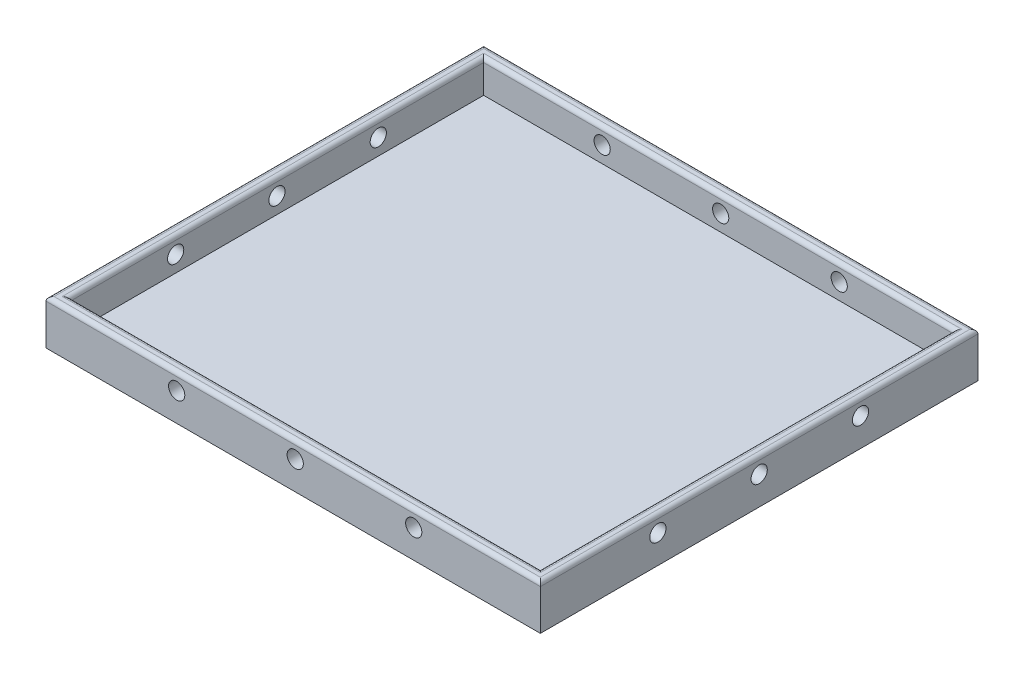
from build123d import *

# Parameters (mm, degrees)
SKETCH1_W               = 122
SKETCH1_H               = 108
BOSS_EXTRUDE1_DEPTH     = 11
SKETCH4_W               = 116
SKETCH4_H               = 102
CUT_EXTRUDE1_DEPTH      = 8
SKETCH6_R               = 1.999999993
SKETCH6_R_2             = 2
CUT_EXTRUDE6_DEPTH      = 120
CUT_EXTRUDE6_DEPTH_BACK = 4
SKETCH5_R               = 2
CUT_EXTRUDE5_DEPTH      = 106
CUT_EXTRUDE5_DEPTH_BACK = 4
FILLET2_R               = 1


with BuildPart() as part:
    # Sketch1 → Boss-Extrude1 (new body)
    with BuildSketch(Plane(origin=(0, 0, 0), x_dir=(1, 0, 0), z_dir=(0, 1, 0))):
        with Locations((-140.609907121, 23.894736842)):
            Rectangle(SKETCH1_W, SKETCH1_H)
    extrude(amount=BOSS_EXTRUDE1_DEPTH)

    # Sketch4 → Cut-Extrude1 (cut)
    with BuildSketch(Plane(origin=(0, 11, 0), x_dir=(1, 0, 0), z_dir=(0, 1, 0))):
        with Locations((-140.609907121, 23.894736842)):
            Rectangle(SKETCH4_W, SKETCH4_H)
    extrude(amount=-CUT_EXTRUDE1_DEPTH, mode=Mode.SUBTRACT)

    # Sketch6 → Cut-Extrude6 (cut, two sides)
    with BuildSketch(Plane(origin=(-198.609907121, 0, 0), x_dir=(0, 0, -1), z_dir=(1, 0, 0))) as cut_extrude6_sk:
        with Locations((-1.105263158, 6.999999977)):
            Circle(SKETCH6_R)
        with Locations((23.894736842, 6.999999988)):
            Circle(SKETCH6_R)
        with Locations((48.894736842, 7)):
            Circle(SKETCH6_R_2)
    extrude(amount=CUT_EXTRUDE6_DEPTH, mode=Mode.SUBTRACT)
    extrude(cut_extrude6_sk.sketch, amount=-CUT_EXTRUDE6_DEPTH_BACK, mode=Mode.SUBTRACT)

    # Sketch5 → Cut-Extrude5 (cut, two sides)
    with BuildSketch(Plane.XY.offset(-74.894736842)) as cut_extrude5_sk:
        with Locations((-169.359907121, 7)):
            Circle(SKETCH5_R)
        with Locations((-140.109907121, 7)):
            Circle(SKETCH5_R)
        with Locations((-110.859907121, 7)):
            Circle(SKETCH5_R)
    extrude(amount=CUT_EXTRUDE5_DEPTH, mode=Mode.SUBTRACT)
    extrude(cut_extrude5_sk.sketch, amount=-CUT_EXTRUDE5_DEPTH_BACK, mode=Mode.SUBTRACT)

    # Fillet2
    fillet2_edges = [part.edges().sort_by_distance(p)[0] for p in [
        (-79.609907121, 11, -23.894736842),
        (-140.609907121, 11, -77.894736842),
        (-198.609907121, 11, -23.894736842),
        (-140.609907121, 11, 27.105263158),
        (-82.609907121, 11, -23.894736842),
        (-140.609907121, 11, -74.894736842),
        (-201.609907121, 11, -23.894736842),
        (-140.609907121, 11, 30.105263158),
    ]]
    fillet(fillet2_edges, radius=FILLET2_R)


solid = part.part
